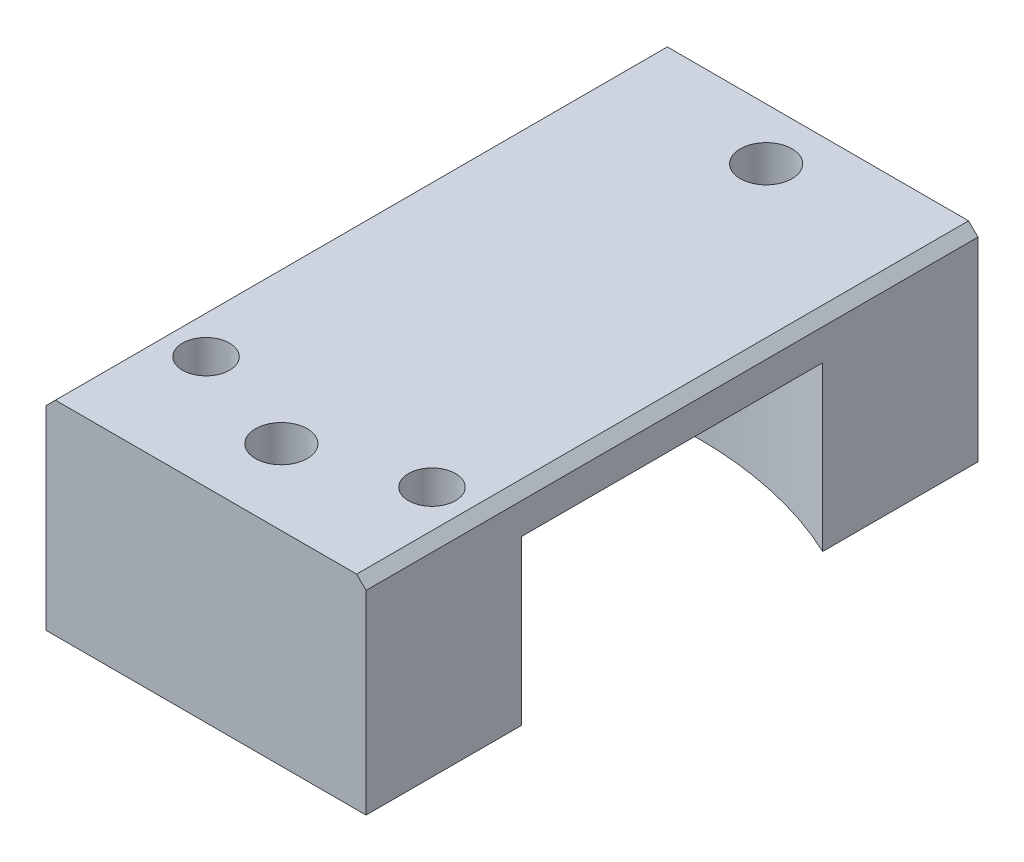
from build123d import *

# Parameters (mm, degrees)
SKIZZE1_R                                            = 52.5
SKIZZE1_R_2                                          = 17.5
AUFSATZ_LINEAR_AUSTRAGEN1_DEPTH                      = 65
SKIZZE18_W                                           = 35.5
SKIZZE18_H                                           = 65
SCHNITT_LINEAR_AUSTRAGEN11_DEPTH                     = 106
SKIZZE25_W                                           = 34
SKIZZE25_H                                           = 81
SCHNITT_LINEAR_AUSTRAGEN12_DEPTH                     = 66
F_5_0_5_DURCHMESSER_BOHRUNG1_D                       = 5
F_5_0_5_DURCHMESSER_BOHRUNG1_DEPTH                   = 12
F_5_0_5_DURCHMESSER_BOHRUNG1_TIP                     = 1.502151548
M4_GEWINDEBOHRUNG1_D                                 = 3.3
STIRNSENKUNG_F_R_M5_ZYLINDERSCHRAUBE_MIT_D           = 5.5
STIRNSENKUNG_F_R_M5_ZYLINDERSCHRAUBE_MIT_CBORE_D     = 10
STIRNSENKUNG_F_R_M5_ZYLINDERSCHRAUBE_MIT_CBORE_DEPTH = 6
FASE1_SIZE                                           = 1
CUT_EXTRUDE1_DEPTH                                   = 20.2
SKETCH1_W                                            = 34
SKETCH1_H                                            = 65
CUT_EXTRUDE2_DEPTH                                   = 2.82858


with BuildPart() as part:
    # Skizze1 → Aufsatz-Linear austragen1 (new body)
    with BuildSketch(Plane.XY):
        Circle(SKIZZE1_R)
        Circle(SKIZZE1_R_2, mode=Mode.SUBTRACT)
    extrude(amount=AUFSATZ_LINEAR_AUSTRAGEN1_DEPTH)

    # Skizze18 → Schnitt-Linear austragen11 (cut, through all)
    with BuildSketch(Plane(origin=(0, -52.5, 0), x_dir=(1, 0, 0), z_dir=(0, 1, 0))):
        with Locations((-34.75, -32.5)):
            Rectangle(SKIZZE18_W, SKIZZE18_H)
        with Locations((34.75, -32.5)):
            Rectangle(SKIZZE18_W, SKIZZE18_H)
    extrude(amount=SCHNITT_LINEAR_AUSTRAGEN11_DEPTH, mode=Mode.SUBTRACT)

    # Skizze25 → Schnitt-Linear austragen12 (cut, through all)
    with BuildSketch(Plane.XY):
        with Locations((0, 12.5)):
            Rectangle(SKIZZE25_W, SKIZZE25_H)
    extrude(amount=SCHNITT_LINEAR_AUSTRAGEN12_DEPTH, mode=Mode.SUBTRACT)

    # 5.0 _5_ Durchmesser Bohrung1
    with Locations(Plane(origin=(0, -28, 0), x_dir=(1, 0, 0), z_dir=(0, 1, 0))):
        with Locations((12, -53), (-12, -53)):
            Hole(F_5_0_5_DURCHMESSER_BOHRUNG1_D / 2, depth=F_5_0_5_DURCHMESSER_BOHRUNG1_DEPTH)
            with Locations((0, 0, -(F_5_0_5_DURCHMESSER_BOHRUNG1_DEPTH + F_5_0_5_DURCHMESSER_BOHRUNG1_TIP / 2))):  # 118° drill point
                Cone(0, F_5_0_5_DURCHMESSER_BOHRUNG1_D / 2, F_5_0_5_DURCHMESSER_BOHRUNG1_TIP, mode=Mode.SUBTRACT)

    # M4 Gewindebohrung1 (through all)
    with Locations(Plane.XZ.offset(52.5)):
        with Locations((-12, 53), (12, 53)):
            Hole(M4_GEWINDEBOHRUNG1_D / 2)

    # Stirnsenkung f_r M5 Zylinderschraube mit (through all)
    with Locations(Plane.XZ.offset(52.5)):
        with Locations((0, 5.5), (0, 57)):
            CounterBoreHole(STIRNSENKUNG_F_R_M5_ZYLINDERSCHRAUBE_MIT_D / 2, STIRNSENKUNG_F_R_M5_ZYLINDERSCHRAUBE_MIT_CBORE_D / 2, STIRNSENKUNG_F_R_M5_ZYLINDERSCHRAUBE_MIT_CBORE_DEPTH)

    # Fase1
    fase1_edges = [part.edges().sort_by_distance(p)[0] for p in [
        (-17, -28, 32.5),
        (17, -28, 32.5),
    ]]
    chamfer(fase1_edges, length=FASE1_SIZE)

    # Skizze3_2 → Cut-Extrude1 (cut)
    with BuildSketch(Plane(origin=(0, -52.5, 0), x_dir=(1, 0, 0), z_dir=(0, 1, 0))):
        with BuildLine():
            Line((17, -48.5), (17, -16.5))
            ThreePointArc((17, -16.5), (0, -12.70773398), (-17, -16.5))
            Line((-17, -16.5), (-17, -48.5))
            ThreePointArc((-17, -48.5), (-11.82232192, -47.038215467), (-6.887645327, -44.894823008))
            ThreePointArc((-6.887645327, -44.894823008), (0, -43.22), (6.887645327, -44.894823008))
            ThreePointArc((6.887645327, -44.894823008), (11.82232192, -47.038215467), (17, -48.5))
        make_face()
    extrude(amount=CUT_EXTRUDE1_DEPTH, mode=Mode.SUBTRACT)

    # Sketch1 → Cut-Extrude2 (cut)
    with BuildSketch(Plane(origin=(0, -52.5, 0), x_dir=(1, 0, 0), z_dir=(0, 1, 0))):
        with Locations((0, -32.5)):
            Rectangle(SKETCH1_W, SKETCH1_H)
    extrude(amount=CUT_EXTRUDE2_DEPTH, mode=Mode.SUBTRACT)


solid = part.part
